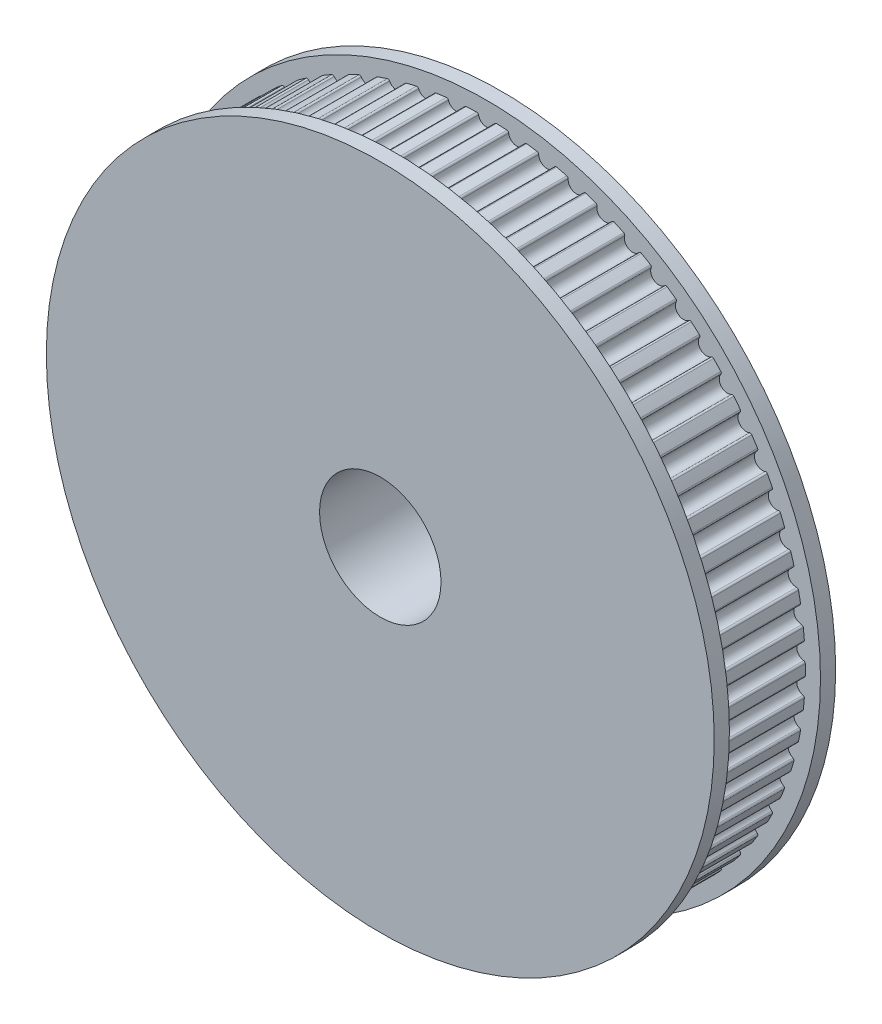
from build123d import *

# Parameters (mm, degrees)
SKETCH1_R           = 4
BOSS_EXTRUDE1_DEPTH = 6
SKETCH3_R           = 22
SKETCH3_R_2         = 4
BOSS_EXTRUDE2_DEPTH = 1
SKETCH4_R           = 22
SKETCH4_R_2         = 4
BOSS_EXTRUDE3_DEPTH = 1


with BuildPart() as part:
    # Sketch1 → Boss-Extrude1 (new body)
    with BuildSketch(Plane.XY):
        with BuildLine():
            ThreePointArc((-0.528729207, 20.890248339), (-0.573745595, 20.963017024), (-0.65501915, 20.989782039))
            ThreePointArc((-0.65501915, 20.989782039), (-0.999220234, 20.976214126), (-1.343152462, 20.95700221))
            ThreePointArc((-1.343152462, 20.95700221), (-1.421513827, 20.922632846), (-1.459409274, 20.845914583))
            ThreePointArc((-1.459409274, 20.845914583), (-1.944846648, 20.367355539), (-2.512079431, 20.745396771))
            ThreePointArc((-2.512079431, 20.745396771), (-2.563809084, 20.813556874), (-2.647258803, 20.832475153))
            ThreePointArc((-2.647258803, 20.832475153), (-2.988611606, 20.786250283), (-3.329160273, 20.734432523))
            ThreePointArc((-3.329160273, 20.734432523), (-3.403899796, 20.692770065), (-3.434331115, 20.612796997))
            ThreePointArc((-3.434331115, 20.612796997), (-3.872080462, 20.090261149), (-4.472679874, 20.412671677))
            ThreePointArc((-4.472679874, 20.412671677), (-4.530654321, 20.47560593), (-4.61552447, 20.486506145))
            ThreePointArc((-4.61552447, 20.486506145), (-4.950937648, 20.408042938), (-5.285018693, 20.324088604))
            ThreePointArc((-5.285018693, 20.324088604), (-5.355459521, 20.275510353), (-5.378151122, 20.193006729))
            ThreePointArc((-5.378151122, 20.193006729), (-5.764248115, 19.631226244), (-6.392775036, 19.895086267))
            ThreePointArc((-6.392775036, 19.895086267), (-6.456469251, 19.952224728), (-6.541991233, 19.955008165))
            ThreePointArc((-6.541991233, 19.955008165), (-6.868427232, 19.845017197), (-7.193015165, 19.729686592))
            ThreePointArc((-7.193015165, 19.729686592), (-7.258519376, 19.674632481), (-7.273265759, 19.590345465))
            ThreePointArc((-7.273265759, 19.590345465), (-7.604213845, 18.994407913), (-8.254976237, 19.197327876))
            ThreePointArc((-8.254976237, 19.197327876), (-8.323813396, 19.248153089), (-8.40921271, 19.242794542))
            ThreePointArc((-8.40921271, 19.242794542), (-8.723715275, 19.102271906), (-9.035870578, 18.956609482))
            ThreePointArc((-9.035870578, 18.956609482), (-9.095844955, 18.89557809), (-9.102512575, 18.810270999))
            ThreePointArc((-9.102512575, 18.810270999), (-9.375314637, 18.185573283), (-10.042419095, 18.32571551))
            ThreePointArc((-10.042419095, 18.32571551), (-10.115775798, 18.369767195), (-10.200279054, 18.356315191))
            ThreePointArc((-10.200279054, 18.356315191), (-10.500000002, 18.186533483), (-10.796895748, 18.011858382))
            ThreePointArc((-10.796895748, 18.011858382), (-10.850797153, 17.945402417), (-10.849325627, 17.859847807))
            ThreePointArc((-10.849325627, 17.859847807), (-11.061511127, 17.212047285), (-11.73891625, 17.288142628))
            ThreePointArc((-11.73891625, 17.288142628), (-11.816128167, 17.325021845), (-11.898970093, 17.303598207))
            ThreePointArc((-11.898970093, 17.303598207), (-12.181195103, 17.106094997), (-12.460142558, 16.903989103))
            ThreePointArc((-12.460142558, 16.903989103), (-12.507482853, 16.832710402), (-12.497885507, 16.747683067))
            ThreePointArc((-12.497885507, 16.747683067), (-12.64753286, 16.082646322), (-13.329103963, 16.094005648))
            ThreePointArc((-13.329103963, 16.094005648), (-13.409471851, 16.123378414), (-13.489902215, 16.094177158))
            ThreePointArc((-13.489902215, 16.094177158), (-13.752075415, 15.870741065), (-14.010548388, 15.643034681))
            ThreePointArc((-14.010548388, 15.643034681), (-14.050898851, 15.567578754), (-14.0332626, 15.483848715))
            ThreePointArc((-14.0332626, 15.483848715), (-14.119016577, 14.807598423), (-14.798581245, 14.754118861))
            ThreePointArc((-14.798581245, 14.754118861), (-14.88137728, 14.775719171), (-14.958667694, 14.739004749))
            ThreePointArc((-14.958667694, 14.739004749), (-15.198414802, 14.491659245), (-15.434072522, 14.240414515))
            ThreePointArc((-15.434072522, 14.240414515), (-15.467067733, 14.161464703), (-15.441552294, 14.079790232))
            ThreePointArc((-15.441552294, 14.079790232), (-15.462636293, 13.39845062), (-16.134040285, 13.280616489))
            ThreePointArc((-16.134040285, 13.280616489), (-16.218514653, 13.294248728), (-16.291965162, 13.250353631))
            ThreePointArc((-16.291965162, 13.250353631), (-16.507114992, 12.981338714), (-16.717823305, 12.70883095))
            ThreePointArc((-16.717823305, 12.70883095), (-16.743164454, 12.627102234), (-16.7100009, 12.548222988))
            ThreePointArc((-16.7100009, 12.548222988), (-16.666223981, 11.867964373), (-17.323386957, 11.686842798))
            ThreePointArc((-17.323386957, 11.686842798), (-17.408774645, 11.692383509), (-17.47772007, 11.641705258))
            ThreePointArc((-17.47772007, 11.641705258), (-17.666324192, 11.35345717), (-17.850174891, 11.062154244))
            ThreePointArc((-17.850174891, 11.062154244), (-17.867632486, 10.978386773), (-17.827121149, 10.903017094))
            ThreePointArc((-17.827121149, 10.903017094), (-17.718879764, 10.230000004), (-18.355850354, 9.987231248))
            ThreePointArc((-18.355850354, 9.987231248), (-18.441378078, 9.984630255), (-18.505194039, 9.927627799))
            ThreePointArc((-18.505194039, 9.927627799), (-18.665544424, 9.62275696), (-18.82087253, 9.315296955))
            ThreePointArc((-18.82087253, 9.315296955), (-18.83028847, 9.23024934), (-18.782796229, 9.159071789))
            ThreePointArc((-18.782796229, 9.159071789), (-18.611070627, 8.49939117), (-19.222080328, 8.197173786))
            ThreePointArc((-19.222080328, 8.197173786), (-19.306973536, 8.186454643), (-19.365082105, 8.123644206))
            ThreePointArc((-19.365082105, 8.123644206), (-19.495726595, 7.804911572), (-19.621125432, 7.484078896))
            ThreePointArc((-19.621125432, 7.484078896), (-19.622414447, 7.39852134), (-19.568371398, 7.332180511))
            ThreePointArc((-19.568371398, 7.332180511), (-19.334716753, 6.691810533), (-19.914232166, 6.332881448))
            ThreePointArc((-19.914232166, 6.332881448), (-19.997722052, 6.31414123), (-20.049596989, 6.246091633))
            ThreePointArc((-20.049596989, 6.246091633), (-20.149352448, 5.916383697), (-20.243686384, 5.585083858))
            ThreePointArc((-20.243686384, 5.585083858), (-20.2368368, 5.499791186), (-20.176732365, 5.438887871))
            ThreePointArc((-20.176732365, 5.438887871), (-19.88326469, 4.823627824), (-20.426037634, 4.411237556))
            ThreePointArc((-20.426037634, 4.411237556), (-20.5073681, 4.384645977), (-20.552539618, 4.311973487))
            ThreePointArc((-20.552539618, 4.311973487), (-20.620502645, 3.974276135), (-20.682917378, 3.635509437))
            ThreePointArc((-20.682917378, 3.635509437), (-20.667991224, 3.551254071), (-20.602369719, 3.496339821))
            ThreePointArc((-20.602369719, 3.496339821), (-20.251746703, 2.911761595), (-20.752861742, 2.449644813))
            ThreePointArc((-20.752861742, 2.449644813), (-20.831296247, 2.41544269), (-20.869355266, 2.338805442))
            ThreePointArc((-20.869355266, 2.338805442), (-20.904910376, 1.996176913), (-20.934840668, 1.653011279))
            ThreePointArc((-20.934840668, 1.653011279), (-20.91197312, 1.570556249), (-20.841428823, 1.522128375))
            ThreePointArc((-20.841428823, 1.522128375), (-20.436825762, 0.973526001), (-20.89174472, 0.465867707))
            ThreePointArc((-20.89174472, 0.465867707), (-20.966572949, 0.424364781), (-20.9971748, 0.344456812))
            ThreePointArc((-20.9971748, 0.344456812), (-21.000000002, 3e-09), (-20.9971748, -0.344456805))
            ThreePointArc((-20.9971748, -0.344456805), (-20.966572949, -0.424364774), (-20.89174472, -0.4658677))
            ThreePointArc((-20.89174472, -0.4658677), (-20.436825762, -0.973525994), (-20.841428823, -1.522128368))
            ThreePointArc((-20.841428823, -1.522128368), (-20.91197312, -1.570556242), (-20.934840668, -1.653011272))
            ThreePointArc((-20.934840668, -1.653011272), (-20.904910376, -1.996176906), (-20.869355266, -2.338805435))
            ThreePointArc((-20.869355266, -2.338805435), (-20.831296247, -2.415442683), (-20.752861742, -2.449644806))
            ThreePointArc((-20.752861742, -2.449644806), (-20.251746703, -2.911761588), (-20.602369719, -3.496339814))
            ThreePointArc((-20.602369719, -3.496339814), (-20.667991224, -3.551254064), (-20.682917378, -3.63550943))
            ThreePointArc((-20.682917378, -3.63550943), (-20.620502645, -3.974276128), (-20.552539618, -4.31197348))
            ThreePointArc((-20.552539618, -4.31197348), (-20.5073681, -4.38464597), (-20.426037634, -4.411237549))
            ThreePointArc((-20.426037634, -4.411237549), (-19.88326469, -4.823627817), (-20.176732365, -5.438887864))
            ThreePointArc((-20.176732365, -5.438887864), (-20.2368368, -5.499791179), (-20.243686384, -5.585083851))
            ThreePointArc((-20.243686384, -5.585083851), (-20.149352448, -5.91638369), (-20.049596989, -6.246091626))
            ThreePointArc((-20.049596989, -6.246091626), (-19.997722052, -6.314141223), (-19.914232166, -6.332881441))
            ThreePointArc((-19.914232166, -6.332881441), (-19.334716753, -6.691810526), (-19.568371398, -7.332180504))
            ThreePointArc((-19.568371398, -7.332180504), (-19.622414447, -7.398521333), (-19.621125432, -7.484078889))
            ThreePointArc((-19.621125432, -7.484078889), (-19.495726595, -7.804911565), (-19.365082105, -8.123644199))
            ThreePointArc((-19.365082105, -8.123644199), (-19.306973536, -8.186454636), (-19.222080328, -8.197173779))
            ThreePointArc((-19.222080328, -8.197173779), (-18.611070627, -8.499391163), (-18.782796229, -9.159071782))
            ThreePointArc((-18.782796229, -9.159071782), (-18.83028847, -9.230249333), (-18.82087253, -9.315296948))
            ThreePointArc((-18.82087253, -9.315296948), (-18.665544424, -9.622756953), (-18.505194039, -9.927627792))
            ThreePointArc((-18.505194039, -9.927627792), (-18.441378078, -9.984630248), (-18.355850354, -9.987231241))
            ThreePointArc((-18.355850354, -9.987231241), (-17.718879764, -10.229999997), (-17.827121149, -10.903017087))
            ThreePointArc((-17.827121149, -10.903017087), (-17.867632486, -10.978386766), (-17.850174891, -11.062154237))
            ThreePointArc((-17.850174891, -11.062154237), (-17.666324192, -11.353457163), (-17.47772007, -11.641705251))
            ThreePointArc((-17.47772007, -11.641705251), (-17.408774645, -11.692383502), (-17.323386957, -11.686842791))
            ThreePointArc((-17.323386957, -11.686842791), (-16.666223981, -11.867964366), (-16.7100009, -12.548222981))
            ThreePointArc((-16.7100009, -12.548222981), (-16.743164454, -12.627102227), (-16.717823305, -12.708830943))
            ThreePointArc((-16.717823305, -12.708830943), (-16.507114992, -12.981338707), (-16.291965162, -13.250353624))
            ThreePointArc((-16.291965162, -13.250353624), (-16.218514653, -13.294248721), (-16.134040285, -13.280616482))
            ThreePointArc((-16.134040285, -13.280616482), (-15.462636293, -13.398450613), (-15.441552294, -14.079790225))
            ThreePointArc((-15.441552294, -14.079790225), (-15.467067733, -14.161464696), (-15.434072522, -14.240414508))
            ThreePointArc((-15.434072522, -14.240414508), (-15.198414802, -14.491659238), (-14.958667694, -14.739004742))
            ThreePointArc((-14.958667694, -14.739004742), (-14.88137728, -14.775719164), (-14.798581245, -14.754118854))
            ThreePointArc((-14.798581245, -14.754118854), (-14.119016577, -14.807598416), (-14.0332626, -15.483848708))
            ThreePointArc((-14.0332626, -15.483848708), (-14.050898851, -15.567578747), (-14.010548388, -15.643034674))
            ThreePointArc((-14.010548388, -15.643034674), (-13.752075415, -15.870741058), (-13.489902215, -16.094177151))
            ThreePointArc((-13.489902215, -16.094177151), (-13.409471851, -16.123378407), (-13.329103963, -16.094005641))
            ThreePointArc((-13.329103963, -16.094005641), (-12.64753286, -16.082646315), (-12.497885507, -16.74768306))
            ThreePointArc((-12.497885507, -16.74768306), (-12.507482853, -16.832710395), (-12.460142558, -16.903989096))
            ThreePointArc((-12.460142558, -16.903989096), (-12.181195103, -17.10609499), (-11.898970093, -17.3035982))
            ThreePointArc((-11.898970093, -17.3035982), (-11.816128167, -17.325021838), (-11.73891625, -17.288142621))
            ThreePointArc((-11.73891625, -17.288142621), (-11.061511127, -17.212047278), (-10.849325627, -17.8598478))
            ThreePointArc((-10.849325627, -17.8598478), (-10.850797153, -17.94540241), (-10.796895748, -18.011858375))
            ThreePointArc((-10.796895748, -18.011858375), (-10.500000002, -18.186533476), (-10.200279054, -18.356315184))
            ThreePointArc((-10.200279054, -18.356315184), (-10.115775798, -18.369767188), (-10.042419095, -18.325715503))
            ThreePointArc((-10.042419095, -18.325715503), (-9.375314637, -18.185573276), (-9.102512575, -18.810270992))
            ThreePointArc((-9.102512575, -18.810270992), (-9.095844955, -18.895578083), (-9.035870578, -18.956609475))
            ThreePointArc((-9.035870578, -18.956609475), (-8.723715275, -19.102271899), (-8.40921271, -19.242794535))
            ThreePointArc((-8.40921271, -19.242794535), (-8.323813396, -19.248153082), (-8.254976237, -19.197327869))
            ThreePointArc((-8.254976237, -19.197327869), (-7.604213845, -18.994407906), (-7.273265759, -19.590345458))
            ThreePointArc((-7.273265759, -19.590345458), (-7.258519376, -19.674632474), (-7.193015165, -19.729686585))
            ThreePointArc((-7.193015165, -19.729686585), (-6.868427232, -19.84501719), (-6.541991233, -19.955008158))
            ThreePointArc((-6.541991233, -19.955008158), (-6.456469251, -19.952224721), (-6.392775036, -19.89508626))
            ThreePointArc((-6.392775036, -19.89508626), (-5.764248115, -19.631226237), (-5.378151122, -20.193006722))
            ThreePointArc((-5.378151122, -20.193006722), (-5.355459521, -20.275510346), (-5.285018693, -20.324088597))
            ThreePointArc((-5.285018693, -20.324088597), (-4.950937648, -20.408042931), (-4.61552447, -20.486506138))
            ThreePointArc((-4.61552447, -20.486506138), (-4.530654321, -20.475605923), (-4.472679874, -20.41267167))
            ThreePointArc((-4.472679874, -20.41267167), (-3.872080462, -20.090261142), (-3.434331115, -20.61279699))
            ThreePointArc((-3.434331115, -20.61279699), (-3.403899796, -20.692770058), (-3.329160273, -20.734432516))
            ThreePointArc((-3.329160273, -20.734432516), (-2.988611606, -20.786250276), (-2.647258803, -20.832475146))
            ThreePointArc((-2.647258803, -20.832475146), (-2.563809084, -20.813556867), (-2.512079431, -20.745396764))
            ThreePointArc((-2.512079431, -20.745396764), (-1.944846648, -20.367355532), (-1.459409274, -20.845914576))
            ThreePointArc((-1.459409274, -20.845914576), (-1.421513827, -20.922632839), (-1.343152462, -20.957002203))
            ThreePointArc((-1.343152462, -20.957002203), (-0.999220234, -20.976214119), (-0.65501915, -20.989782032))
            ThreePointArc((-0.65501915, -20.989782032), (-0.573745595, -20.963017017), (-0.528729207, -20.890248332))
            ThreePointArc((-0.528729207, -20.890248332), (-2e-09, -20.459999997), (0.528729203, -20.890248332))
            ThreePointArc((0.528729203, -20.890248332), (0.573745591, -20.963017017), (0.655019146, -20.989782032))
            ThreePointArc((0.655019146, -20.989782032), (0.99922023, -20.976214119), (1.343152458, -20.957002203))
            ThreePointArc((1.343152458, -20.957002203), (1.421513823, -20.922632839), (1.45940927, -20.845914576))
            ThreePointArc((1.45940927, -20.845914576), (1.944846644, -20.367355532), (2.512079426, -20.745396764))
            ThreePointArc((2.512079426, -20.745396764), (2.56380908, -20.813556867), (2.647258799, -20.832475146))
            ThreePointArc((2.647258799, -20.832475146), (2.988611602, -20.786250276), (3.329160268, -20.734432516))
            ThreePointArc((3.329160268, -20.734432516), (3.403899792, -20.692770058), (3.434331111, -20.61279699))
            ThreePointArc((3.434331111, -20.61279699), (3.872080458, -20.090261142), (4.47267987, -20.41267167))
            ThreePointArc((4.47267987, -20.41267167), (4.530654317, -20.475605923), (4.615524466, -20.486506138))
            ThreePointArc((4.615524466, -20.486506138), (4.950937644, -20.408042931), (5.285018688, -20.324088597))
            ThreePointArc((5.285018688, -20.324088597), (5.355459517, -20.275510346), (5.378151117, -20.193006722))
            ThreePointArc((5.378151117, -20.193006722), (5.764248111, -19.631226237), (6.392775031, -19.89508626))
            ThreePointArc((6.392775031, -19.89508626), (6.456469247, -19.952224721), (6.541991229, -19.955008158))
            ThreePointArc((6.541991229, -19.955008158), (6.868427228, -19.84501719), (7.193015161, -19.729686585))
            ThreePointArc((7.193015161, -19.729686585), (7.258519372, -19.674632474), (7.273265754, -19.590345458))
            ThreePointArc((7.273265754, -19.590345458), (7.604213841, -18.994407906), (8.254976233, -19.197327869))
            ThreePointArc((8.254976233, -19.197327869), (8.323813392, -19.248153082), (8.409212706, -19.242794535))
            ThreePointArc((8.409212706, -19.242794535), (8.723715271, -19.102271899), (9.035870574, -18.956609475))
            ThreePointArc((9.035870574, -18.956609475), (9.095844951, -18.895578083), (9.102512571, -18.810270992))
            ThreePointArc((9.102512571, -18.810270992), (9.375314632, -18.185573276), (10.042419091, -18.325715503))
            ThreePointArc((10.042419091, -18.325715503), (10.115775794, -18.369767188), (10.20027905, -18.356315184))
            ThreePointArc((10.20027905, -18.356315184), (10.499999998, -18.186533476), (10.796895744, -18.011858375))
            ThreePointArc((10.796895744, -18.011858375), (10.850797149, -17.94540241), (10.849325623, -17.8598478))
            ThreePointArc((10.849325623, -17.8598478), (11.061511123, -17.212047278), (11.738916246, -17.288142621))
            ThreePointArc((11.738916246, -17.288142621), (11.816128163, -17.325021838), (11.898970088, -17.3035982))
            ThreePointArc((11.898970088, -17.3035982), (12.181195099, -17.10609499), (12.460142554, -16.903989096))
            ThreePointArc((12.460142554, -16.903989096), (12.507482849, -16.832710395), (12.497885503, -16.74768306))
            ThreePointArc((12.497885503, -16.74768306), (12.647532856, -16.082646315), (13.329103958, -16.094005641))
            ThreePointArc((13.329103958, -16.094005641), (13.409471846, -16.123378407), (13.489902211, -16.094177151))
            ThreePointArc((13.489902211, -16.094177151), (13.752075411, -15.870741058), (14.010548383, -15.643034674))
            ThreePointArc((14.010548383, -15.643034674), (14.050898846, -15.567578747), (14.033262596, -15.483848708))
            ThreePointArc((14.033262596, -15.483848708), (14.119016573, -14.807598416), (14.798581241, -14.754118854))
            ThreePointArc((14.798581241, -14.754118854), (14.881377276, -14.775719164), (14.95866769, -14.739004742))
            ThreePointArc((14.95866769, -14.739004742), (15.198414798, -14.491659238), (15.434072517, -14.240414508))
            ThreePointArc((15.434072517, -14.240414508), (15.467067728, -14.161464696), (15.44155229, -14.079790225))
            ThreePointArc((15.44155229, -14.079790225), (15.462636289, -13.398450613), (16.13404028, -13.280616482))
            ThreePointArc((16.13404028, -13.280616482), (16.218514649, -13.294248721), (16.291965157, -13.250353624))
            ThreePointArc((16.291965157, -13.250353624), (16.507114988, -12.981338707), (16.7178233, -12.708830943))
            ThreePointArc((16.7178233, -12.708830943), (16.74316445, -12.627102227), (16.710000896, -12.548222981))
            ThreePointArc((16.710000896, -12.548222981), (16.666223977, -11.867964366), (17.323386953, -11.686842791))
            ThreePointArc((17.323386953, -11.686842791), (17.408774641, -11.692383502), (17.477720066, -11.641705251))
            ThreePointArc((17.477720066, -11.641705251), (17.666324187, -11.353457163), (17.850174887, -11.062154237))
            ThreePointArc((17.850174887, -11.062154237), (17.867632481, -10.978386766), (17.827121145, -10.903017087))
            ThreePointArc((17.827121145, -10.903017087), (17.718879759, -10.229999997), (18.35585035, -9.987231241))
            ThreePointArc((18.35585035, -9.987231241), (18.441378074, -9.984630248), (18.505194035, -9.927627792))
            ThreePointArc((18.505194035, -9.927627792), (18.66554442, -9.622756953), (18.820872525, -9.315296948))
            ThreePointArc((18.820872525, -9.315296948), (18.830288466, -9.230249333), (18.782796225, -9.159071782))
            ThreePointArc((18.782796225, -9.159071782), (18.611070623, -8.499391163), (19.222080324, -8.197173779))
            ThreePointArc((19.222080324, -8.197173779), (19.306973532, -8.186454636), (19.365082101, -8.123644199))
            ThreePointArc((19.365082101, -8.123644199), (19.495726591, -7.804911565), (19.621125428, -7.484078889))
            ThreePointArc((19.621125428, -7.484078889), (19.622414443, -7.398521333), (19.568371394, -7.332180504))
            ThreePointArc((19.568371394, -7.332180504), (19.334716749, -6.691810526), (19.914232162, -6.332881441))
            ThreePointArc((19.914232162, -6.332881441), (19.997722048, -6.314141223), (20.049596985, -6.246091626))
            ThreePointArc((20.049596985, -6.246091626), (20.149352444, -5.91638369), (20.24368638, -5.585083851))
            ThreePointArc((20.24368638, -5.585083851), (20.236836795, -5.499791179), (20.176732361, -5.438887864))
            ThreePointArc((20.176732361, -5.438887864), (19.883264686, -4.823627817), (20.42603763, -4.411237549))
            ThreePointArc((20.42603763, -4.411237549), (20.507368096, -4.38464597), (20.552539614, -4.31197348))
            ThreePointArc((20.552539614, -4.31197348), (20.62050264, -3.974276128), (20.682917373, -3.63550943))
            ThreePointArc((20.682917373, -3.63550943), (20.66799122, -3.551254064), (20.602369715, -3.496339814))
            ThreePointArc((20.602369715, -3.496339814), (20.251746699, -2.911761588), (20.752861738, -2.449644806))
            ThreePointArc((20.752861738, -2.449644806), (20.831296243, -2.415442683), (20.869355262, -2.338805435))
            ThreePointArc((20.869355262, -2.338805435), (20.904910372, -1.996176906), (20.934840664, -1.653011272))
            ThreePointArc((20.934840664, -1.653011272), (20.911973116, -1.570556242), (20.841428819, -1.522128368))
            ThreePointArc((20.841428819, -1.522128368), (20.436825758, -0.973525994), (20.891744716, -0.4658677))
            ThreePointArc((20.891744716, -0.4658677), (20.966572945, -0.424364774), (20.997174796, -0.344456805))
            ThreePointArc((20.997174796, -0.344456805), (20.999999998, 3e-09), (20.997174796, 0.344456812))
            ThreePointArc((20.997174796, 0.344456812), (20.966572945, 0.424364781), (20.891744716, 0.465867707))
            ThreePointArc((20.891744716, 0.465867707), (20.436825758, 0.973526001), (20.841428819, 1.522128375))
            ThreePointArc((20.841428819, 1.522128375), (20.911973116, 1.570556249), (20.934840664, 1.653011279))
            ThreePointArc((20.934840664, 1.653011279), (20.904910372, 1.996176913), (20.869355262, 2.338805442))
            ThreePointArc((20.869355262, 2.338805442), (20.831296243, 2.41544269), (20.752861738, 2.449644813))
            ThreePointArc((20.752861738, 2.449644813), (20.251746699, 2.911761595), (20.602369715, 3.496339821))
            ThreePointArc((20.602369715, 3.496339821), (20.66799122, 3.551254071), (20.682917373, 3.635509437))
            ThreePointArc((20.682917373, 3.635509437), (20.62050264, 3.974276135), (20.552539614, 4.311973487))
            ThreePointArc((20.552539614, 4.311973487), (20.507368096, 4.384645977), (20.42603763, 4.411237556))
            ThreePointArc((20.42603763, 4.411237556), (19.883264686, 4.823627824), (20.176732361, 5.438887871))
            ThreePointArc((20.176732361, 5.438887871), (20.236836795, 5.499791186), (20.24368638, 5.585083858))
            ThreePointArc((20.24368638, 5.585083858), (20.149352444, 5.916383697), (20.049596985, 6.246091633))
            ThreePointArc((20.049596985, 6.246091633), (19.997722048, 6.31414123), (19.914232162, 6.332881448))
            ThreePointArc((19.914232162, 6.332881448), (19.334716749, 6.691810533), (19.568371394, 7.332180511))
            ThreePointArc((19.568371394, 7.332180511), (19.622414443, 7.39852134), (19.621125428, 7.484078896))
            ThreePointArc((19.621125428, 7.484078896), (19.495726591, 7.804911572), (19.365082101, 8.123644206))
            ThreePointArc((19.365082101, 8.123644206), (19.306973532, 8.186454643), (19.222080324, 8.197173786))
            ThreePointArc((19.222080324, 8.197173786), (18.611070623, 8.49939117), (18.782796225, 9.159071789))
            ThreePointArc((18.782796225, 9.159071789), (18.830288466, 9.23024934), (18.820872525, 9.315296955))
            ThreePointArc((18.820872525, 9.315296955), (18.66554442, 9.62275696), (18.505194035, 9.927627799))
            ThreePointArc((18.505194035, 9.927627799), (18.441378074, 9.984630255), (18.35585035, 9.987231248))
            ThreePointArc((18.35585035, 9.987231248), (17.718879759, 10.230000004), (17.827121145, 10.903017094))
            ThreePointArc((17.827121145, 10.903017094), (17.867632481, 10.978386773), (17.850174887, 11.062154244))
            ThreePointArc((17.850174887, 11.062154244), (17.666324187, 11.35345717), (17.477720066, 11.641705258))
            ThreePointArc((17.477720066, 11.641705258), (17.408774641, 11.692383509), (17.323386953, 11.686842798))
            ThreePointArc((17.323386953, 11.686842798), (16.666223977, 11.867964373), (16.710000896, 12.548222988))
            ThreePointArc((16.710000896, 12.548222988), (16.74316445, 12.627102234), (16.7178233, 12.70883095))
            ThreePointArc((16.7178233, 12.70883095), (16.507114988, 12.981338714), (16.291965157, 13.250353631))
            ThreePointArc((16.291965157, 13.250353631), (16.218514649, 13.294248728), (16.13404028, 13.280616489))
            ThreePointArc((16.13404028, 13.280616489), (15.462636289, 13.39845062), (15.44155229, 14.079790232))
            ThreePointArc((15.44155229, 14.079790232), (15.467067728, 14.161464703), (15.434072517, 14.240414515))
            ThreePointArc((15.434072517, 14.240414515), (15.198414798, 14.491659245), (14.95866769, 14.739004749))
            ThreePointArc((14.95866769, 14.739004749), (14.881377276, 14.775719171), (14.798581241, 14.754118861))
            ThreePointArc((14.798581241, 14.754118861), (14.119016573, 14.807598423), (14.033262596, 15.483848715))
            ThreePointArc((14.033262596, 15.483848715), (14.050898846, 15.567578754), (14.010548383, 15.643034681))
            ThreePointArc((14.010548383, 15.643034681), (13.752075411, 15.870741065), (13.489902211, 16.094177158))
            ThreePointArc((13.489902211, 16.094177158), (13.409471846, 16.123378414), (13.329103958, 16.094005648))
            ThreePointArc((13.329103958, 16.094005648), (12.647532856, 16.082646322), (12.497885503, 16.747683067))
            ThreePointArc((12.497885503, 16.747683067), (12.507482849, 16.832710402), (12.460142554, 16.903989103))
            ThreePointArc((12.460142554, 16.903989103), (12.181195099, 17.106094997), (11.898970088, 17.303598207))
            ThreePointArc((11.898970088, 17.303598207), (11.816128163, 17.325021845), (11.738916246, 17.288142628))
            ThreePointArc((11.738916246, 17.288142628), (11.061511123, 17.212047285), (10.849325623, 17.859847807))
            ThreePointArc((10.849325623, 17.859847807), (10.850797149, 17.945402417), (10.796895744, 18.011858382))
            ThreePointArc((10.796895744, 18.011858382), (10.499999998, 18.186533483), (10.20027905, 18.356315191))
            ThreePointArc((10.20027905, 18.356315191), (10.115775794, 18.369767195), (10.042419091, 18.32571551))
            ThreePointArc((10.042419091, 18.32571551), (9.375314632, 18.185573283), (9.102512571, 18.810270999))
            ThreePointArc((9.102512571, 18.810270999), (9.095844951, 18.89557809), (9.035870574, 18.956609482))
            ThreePointArc((9.035870574, 18.956609482), (8.723715271, 19.102271906), (8.409212706, 19.242794542))
            ThreePointArc((8.409212706, 19.242794542), (8.323813392, 19.248153089), (8.254976233, 19.197327876))
            ThreePointArc((8.254976233, 19.197327876), (7.604213841, 18.994407913), (7.273265754, 19.590345465))
            ThreePointArc((7.273265754, 19.590345465), (7.258519372, 19.674632481), (7.193015161, 19.729686592))
            ThreePointArc((7.193015161, 19.729686592), (6.868427228, 19.845017197), (6.541991229, 19.955008165))
            ThreePointArc((6.541991229, 19.955008165), (6.456469247, 19.952224728), (6.392775031, 19.895086267))
            ThreePointArc((6.392775031, 19.895086267), (5.764248111, 19.631226244), (5.378151117, 20.193006729))
            ThreePointArc((5.378151117, 20.193006729), (5.355459517, 20.275510353), (5.285018688, 20.324088604))
            ThreePointArc((5.285018688, 20.324088604), (4.950937644, 20.408042938), (4.615524466, 20.486506145))
            ThreePointArc((4.615524466, 20.486506145), (4.530654317, 20.47560593), (4.47267987, 20.412671677))
            ThreePointArc((4.47267987, 20.412671677), (3.872080458, 20.090261149), (3.434331111, 20.612796997))
            ThreePointArc((3.434331111, 20.612796997), (3.403899792, 20.692770065), (3.329160268, 20.734432523))
            ThreePointArc((3.329160268, 20.734432523), (2.988611602, 20.786250283), (2.647258799, 20.832475153))
            ThreePointArc((2.647258799, 20.832475153), (2.56380908, 20.813556874), (2.512079426, 20.745396771))
            ThreePointArc((2.512079426, 20.745396771), (1.944846644, 20.367355539), (1.45940927, 20.845914583))
            ThreePointArc((1.45940927, 20.845914583), (1.421513823, 20.922632846), (1.343152458, 20.95700221))
            ThreePointArc((1.343152458, 20.95700221), (0.99922023, 20.976214126), (0.655019146, 20.989782039))
            ThreePointArc((0.655019146, 20.989782039), (0.573745591, 20.963017024), (0.528729203, 20.890248339))
            ThreePointArc((0.528729203, 20.890248339), (-2e-09, 20.460000004), (-0.528729207, 20.890248339))
        make_face()
        Circle(SKETCH1_R, mode=Mode.SUBTRACT)
    extrude(amount=BOSS_EXTRUDE1_DEPTH)

    # Sketch3 → Boss-Extrude2 (add)
    with BuildSketch(Plane.XY.offset(6)):
        Circle(SKETCH3_R)
        Circle(SKETCH3_R_2, mode=Mode.SUBTRACT)
    extrude(amount=BOSS_EXTRUDE2_DEPTH)

    # Sketch4 → Boss-Extrude3 (add)
    with BuildSketch(Plane(origin=(0, 0, 0), x_dir=(-1, 0, 0), z_dir=(0, 0, -1))):
        Circle(SKETCH4_R)
        Circle(SKETCH4_R_2, mode=Mode.SUBTRACT)
    extrude(amount=BOSS_EXTRUDE3_DEPTH)


solid = part.part
